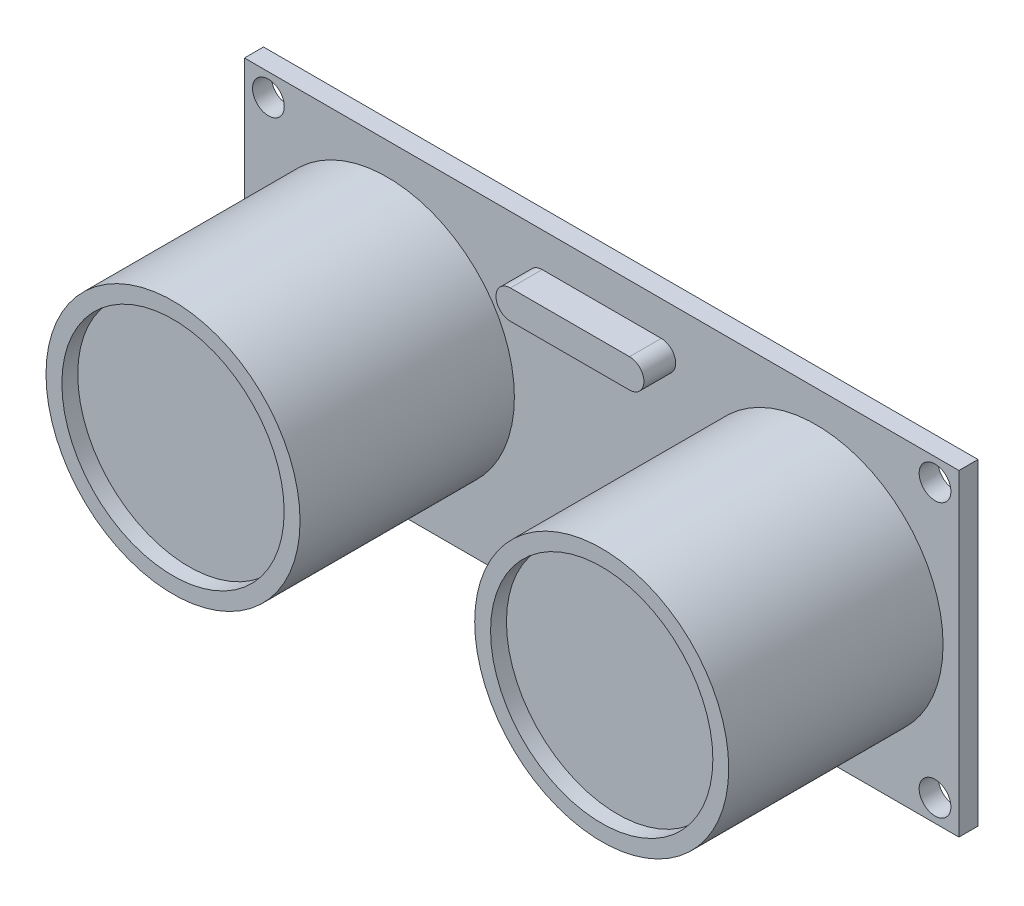
from build123d import *

# Parameters (mm, degrees)
SKETCH1_W             = 45
SKETCH1_H             = 20
SKETCH1_R             = 1
BOSS_EXTRUDE3_DEPTH   = 1.2
SKETCH5_R             = 8
SKETCH5_R_2           = 7
EXTRUDE_THIN1_DEPTH   = 13.5
EXTRUDE_THIN1_2_DEPTH = 13.5
BOSS_EXTRUDE4_DEPTH   = 2
SKETCH11_R            = 7
BOSS_EXTRUDE5_DEPTH   = 12.5
SKETCH12_W            = 1.04
SKETCH12_H            = 1.04
BOSS_EXTRUDE6_DEPTH   = 1
BOSS_EXTRUDE6_2_DEPTH = 1
BOSS_EXTRUDE6_3_DEPTH = 1
BOSS_EXTRUDE6_4_DEPTH = 1
SKETCH16_W            = 0.53517923
SKETCH16_H            = 0.53517923
BOSS_EXTRUDE7_DEPTH   = 2
SKETCH16_H_2          = 0.535179229
BOSS_EXTRUDE7_2_DEPTH = 2
SKETCH16_W_2          = 0.535179229
BOSS_EXTRUDE7_3_DEPTH = 2
BOSS_EXTRUDE7_4_DEPTH = 2


with BuildPart() as part:
    # Sketch1 → Boss-Extrude3 (new body)
    with BuildSketch(Plane.XY):
        Rectangle(SKETCH1_W, SKETCH1_H)
        with Locations((-20.993468664, 8.6)):
            Circle(SKETCH1_R, mode=Mode.SUBTRACT)
        with Locations((-20.993468664, -8.6)):
            Circle(SKETCH1_R, mode=Mode.SUBTRACT)
        with Locations((20.993468664, -8.6)):
            Circle(SKETCH1_R, mode=Mode.SUBTRACT)
        with Locations((20.993468664, 8.6)):
            Circle(SKETCH1_R, mode=Mode.SUBTRACT)
    extrude(amount=BOSS_EXTRUDE3_DEPTH)

    # Sketch8 → Boss-Extrude4 (add)
    with BuildSketch(Plane.XY.offset(1.2)):
        with BuildLine():
            Line((-3.75, 7.831608298), (3.75, 7.831608298))
            ThreePointArc((3.75, 7.831608298), (4.659242449, 6.922365849), (3.75, 6.013123399))
            Line((3.75, 6.013123399), (-3.75, 6.013123399))
            ThreePointArc((-3.75, 6.013123399), (-4.659242449, 6.922365849), (-3.75, 7.831608298))
        make_face()
    extrude(amount=BOSS_EXTRUDE4_DEPTH)



with BuildPart() as body_2:
    # Sketch5 → Extrude-Thin1 (new body)
    with BuildSketch(Plane.XY.offset(1.2)):
        with Locations((-13.5, 0)):
            Circle(SKETCH5_R)
        with Locations((-13.5, 0)):
            Circle(SKETCH5_R_2, mode=Mode.SUBTRACT)
    extrude(amount=EXTRUDE_THIN1_DEPTH)


with BuildPart() as body_3:
    # Sketch5 → Extrude-Thin1 2 (new body)
    with BuildSketch(Plane.XY.offset(1.2)):
        with Locations((13.5, 0)):
            Circle(SKETCH5_R)
        with Locations((13.5, 0)):
            Circle(SKETCH5_R_2, mode=Mode.SUBTRACT)
    extrude(amount=EXTRUDE_THIN1_2_DEPTH)


with BuildPart() as part_1:
    add(part.part)

    add(body_2.part)  # Boss-Extrude5 merges body 2

    add(body_3.part)  # Boss-Extrude5 merges body 3
    # Sketch11 → Boss-Extrude5 (add)
    with BuildSketch(Plane.XY.offset(1.2)):
        with Locations((-13.5, 0)):
            Circle(SKETCH11_R)
        with Locations((13.5, 0)):
            Circle(SKETCH11_R)
    extrude(amount=BOSS_EXTRUDE5_DEPTH)


with BuildPart() as body_2_2:
    # Sketch12 → Boss-Extrude6 (new body)
    with BuildSketch(Plane(origin=(0, 0, 0), x_dir=(-1, 0, 0), z_dir=(0, 0, -1))):
        with Locations((1.52, -8.260870843)):
            Rectangle(SKETCH12_W, SKETCH12_H)
    extrude(amount=BOSS_EXTRUDE6_DEPTH)


with BuildPart() as body_3_2:
    # Sketch12 → Boss-Extrude6 2 (new body)
    with BuildSketch(Plane(origin=(0, 0, 0), x_dir=(-1, 0, 0), z_dir=(0, 0, -1))):
        with Locations((-1.52, -8.260870843)):
            Rectangle(SKETCH12_W, SKETCH12_H)
    extrude(amount=BOSS_EXTRUDE6_2_DEPTH)


with BuildPart() as body_4:
    # Sketch12 → Boss-Extrude6 3 (new body)
    with BuildSketch(Plane(origin=(0, 0, 0), x_dir=(-1, 0, 0), z_dir=(0, 0, -1))):
        with Locations((-4.56, -8.260870843)):
            Rectangle(SKETCH12_W, SKETCH12_H)
    extrude(amount=BOSS_EXTRUDE6_3_DEPTH)


with BuildPart() as body_5:
    # Sketch12 → Boss-Extrude6 4 (new body)
    with BuildSketch(Plane(origin=(0, 0, 0), x_dir=(-1, 0, 0), z_dir=(0, 0, -1))):
        with Locations((4.56, -8.260870843)):
            Rectangle(SKETCH12_W, SKETCH12_H)
    extrude(amount=BOSS_EXTRUDE6_4_DEPTH)


with BuildPart() as body_6:
    # Sketch16 → Boss-Extrude7 (new body)
    with BuildSketch(Plane.XZ.offset(8.780870843)):
        with Locations((-4.538269148, -0.437455606)):
            Rectangle(SKETCH16_W, SKETCH16_H)
    extrude(amount=BOSS_EXTRUDE7_DEPTH)


with BuildPart() as body_7:
    # Sketch16 → Boss-Extrude7 2 (new body)
    with BuildSketch(Plane.XZ.offset(8.780870843)):
        with Locations((-1.470019189, -0.493301318)):
            Rectangle(SKETCH16_W, SKETCH16_H_2)
    extrude(amount=BOSS_EXTRUDE7_2_DEPTH)


with BuildPart() as body_8:
    # Sketch16 → Boss-Extrude7 3 (new body)
    with BuildSketch(Plane.XZ.offset(8.780870843)):
        with Locations((1.556715092, -0.482132175)):
            Rectangle(SKETCH16_W_2, SKETCH16_H)
    extrude(amount=BOSS_EXTRUDE7_3_DEPTH)


with BuildPart() as body_9:
    # Sketch16 → Boss-Extrude7 4 (new body)
    with BuildSketch(Plane.XZ.offset(8.780870843)):
        with Locations((4.566401051, -0.459793891)):
            Rectangle(SKETCH16_W, SKETCH16_H)
    extrude(amount=BOSS_EXTRUDE7_4_DEPTH)


solid = Compound([part_1.part, body_2_2.part, body_3_2.part, body_4.part, body_5.part, body_6.part, body_7.part, body_8.part, body_9.part])
